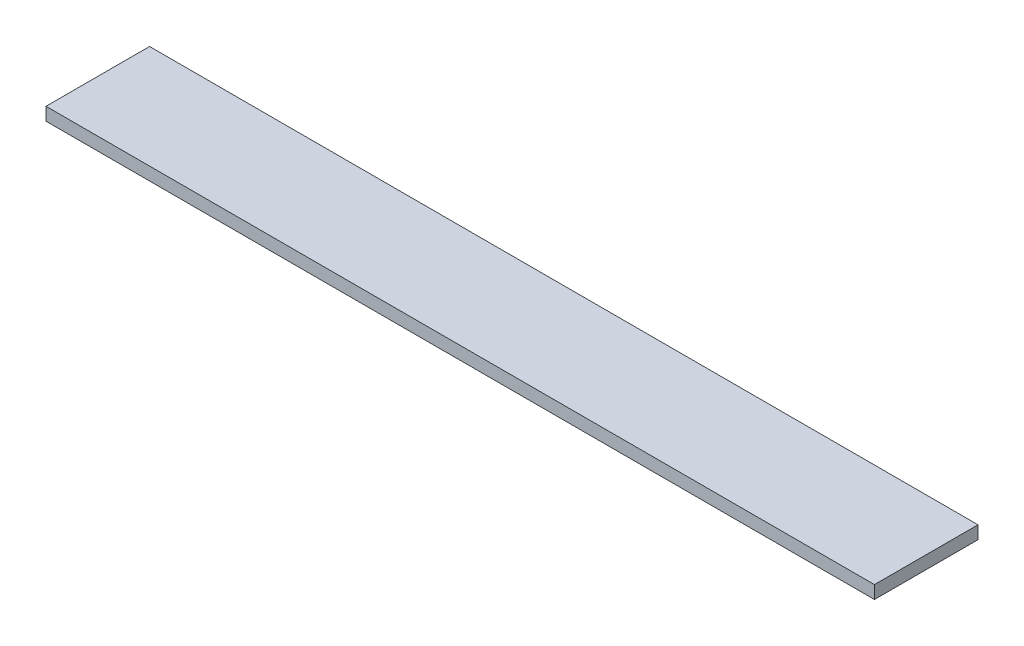
from build123d import *

# Parameters (mm, degrees)
SKETCH1_W           = 609.6
SKETCH1_H           = 76.2
BOSS_EXTRUDE1_DEPTH = 9.525


with BuildPart() as part:
    # Sketch1 → Boss-Extrude1 (new body)
    with BuildSketch(Plane(origin=(0, 0, 0), x_dir=(1, 0, 0), z_dir=(0, 1, 0))):
        with Locations((304.8, 38.1)):
            Rectangle(SKETCH1_W, SKETCH1_H)
    extrude(amount=BOSS_EXTRUDE1_DEPTH)


solid = part.part
